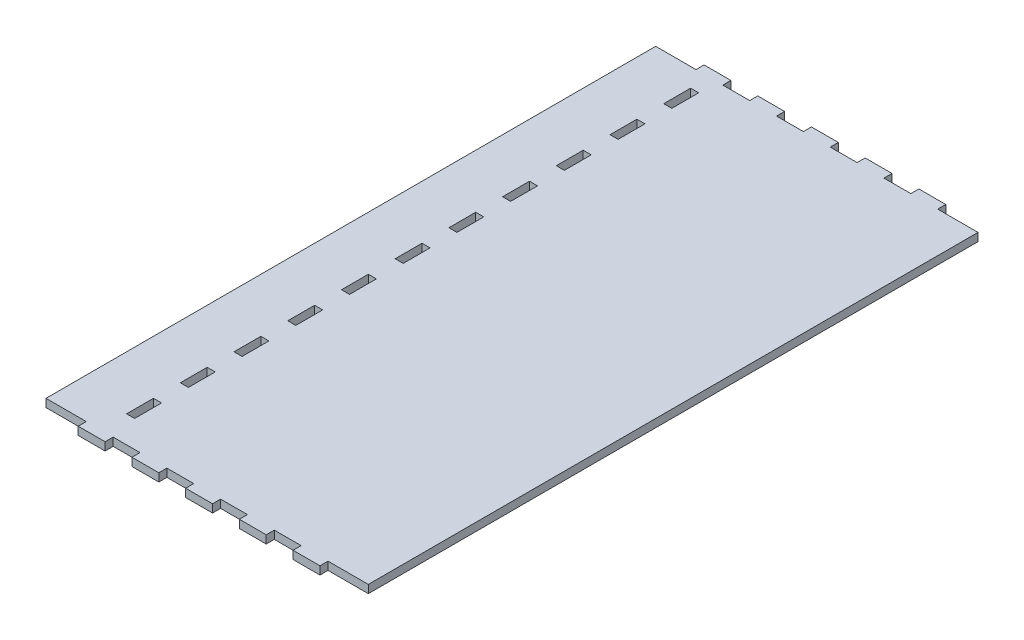
from build123d import *

# Parameters (mm, degrees)
SKETCH1_W           = 120
SKETCH1_H           = 227
BOSS_EXTRUDE1_DEPTH = 3
SKETCH2_W           = 10
SKETCH2_H           = 3
BOSS_EXTRUDE2_DEPTH = 3
LPATTERN1_COUNT     = 5
LPATTERN1_PITCH     = 20
SKETCH3_W           = 10
SKETCH3_H           = 3
BOSS_EXTRUDE3_DEPTH = 3
LPATTERN2_COUNT     = 5
LPATTERN2_PITCH     = 20
SKETCH4_W           = 3
SKETCH4_H           = 10
CUT_EXTRUDE1_DEPTH  = 4
LPATTERN3_COUNT     = 11
LPATTERN3_PITCH     = 20


with BuildPart() as part:
    # Sketch1 → Boss-Extrude1 (new body)
    with BuildSketch(Plane(origin=(0, 0, 0), x_dir=(1, 0, 0), z_dir=(0, 1, 0))):
        with Locations((60, 113.5)):
            Rectangle(SKETCH1_W, SKETCH1_H)
    extrude(amount=BOSS_EXTRUDE1_DEPTH)

    # Sketch2 → Boss-Extrude2 (add)
    with BuildSketch(Plane.XY):
        with Locations((20, 1.5)):
            Rectangle(SKETCH2_W, SKETCH2_H)
    boss_extrude2 = extrude(amount=BOSS_EXTRUDE2_DEPTH)

    # LPattern1: Boss-Extrude2 ×5
    with Locations(*[(i * LPATTERN1_PITCH, 0, 0) for i in range(1, LPATTERN1_COUNT)]):
        add(boss_extrude2)

    # Sketch3 → Boss-Extrude3 (add)
    with BuildSketch(Plane(origin=(0, 0, -227), x_dir=(-1, 0, 0), z_dir=(0, 0, -1))):
        with Locations((-100, 1.5)):
            Rectangle(SKETCH3_W, SKETCH3_H)
    boss_extrude3 = extrude(amount=BOSS_EXTRUDE3_DEPTH)

    # LPattern2: Boss-Extrude3 ×5
    with Locations(*[(-i * LPATTERN2_PITCH, 0, 0) for i in range(1, LPATTERN2_COUNT)]):
        add(boss_extrude3)

    # Sketch4 → Cut-Extrude1 (cut, through all)
    with BuildSketch(Plane(origin=(0, 3, 0), x_dir=(1, 0, 0), z_dir=(0, 1, 0))):
        with Locations((21.5, 15)):
            Rectangle(SKETCH4_W, SKETCH4_H)
    cut_extrude1 = extrude(amount=-CUT_EXTRUDE1_DEPTH, mode=Mode.SUBTRACT)

    # LPattern3: Cut-Extrude1 ×11
    with Locations(*[(0, 0, -i * LPATTERN3_PITCH) for i in range(1, LPATTERN3_COUNT)]):
        add(cut_extrude1, mode=Mode.SUBTRACT)


solid = part.part
